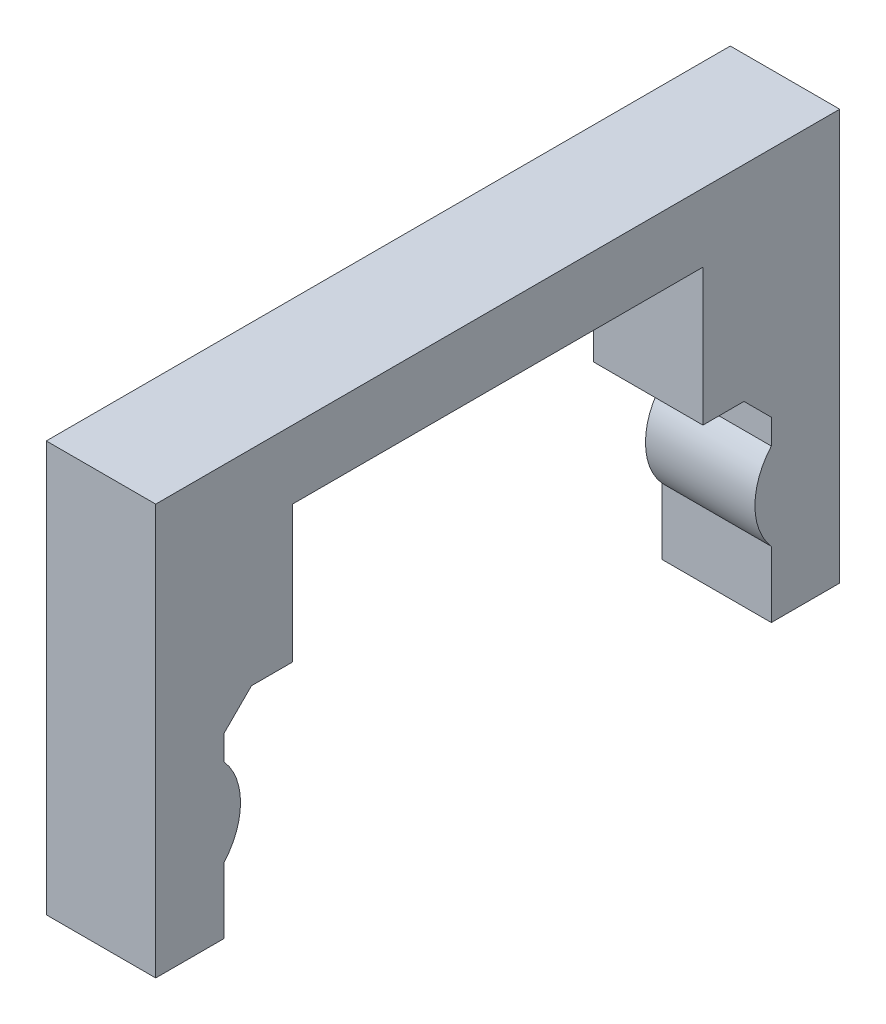
from build123d import *

# Parameters (mm, degrees)
BOSS_EXTRUDE1_DEPTH = 10.16
BOSS_EXTRUDE2_DEPTH = 10.16
CHAMFER1_SIZE       = 2.54


with BuildPart() as part:
    # Sketch3 → Boss-Extrude1 (new body)
    with BuildSketch(Plane(origin=(0, 0, 0), x_dir=(0, 0, -1), z_dir=(1, 0, 0))):
        Polygon((-101.845577666, -9.102652747), (-95.495577666, -9.102652747), (-95.495577666, 9.947347253), (-89.145577666, 9.947347253), (-89.145577666, 22.647347253), (-51.045577666, 22.647347253), (-51.045577666, 9.947347253), (-44.695577666, 9.947347253), (-44.695577666, -9.102652747), (-38.345577666, -9.102652747), (-38.345577666, 28.997347253), (-101.845577666, 28.997347253), align=None)
    extrude(amount=BOSS_EXTRUDE1_DEPTH)

    # Sketch4 → Boss-Extrude2 (add)
    with BuildSketch(Plane(origin=(10.16, 0, 0), x_dir=(0, 0, -1), z_dir=(1, 0, 0))):
        with BuildLine():
            Line((-101.845577666, -4.773598811), (-101.845577666, 6.888293317))
            ThreePointArc((-101.845577666, 6.888293317), (-93.971577666, 1.057347253), (-101.845577666, -4.773598811))
        make_face()
        with BuildLine():
            Line((-38.345577666, -4.773598811), (-38.345577666, 6.888293317))
            ThreePointArc((-38.345577666, 6.888293317), (-46.219577666, 1.057347253), (-38.345577666, -4.773598811))
        make_face()
    extrude(amount=-BOSS_EXTRUDE2_DEPTH)

    # Chamfer1
    chamfer1_edges = [part.edges().sort_by_distance(p)[0] for p in [
        (5.08, 9.947347253, 44.695577666),
        (5.08, 9.947347253, 95.495577666),
    ]]
    chamfer(chamfer1_edges, length=CHAMFER1_SIZE)


solid = part.part
